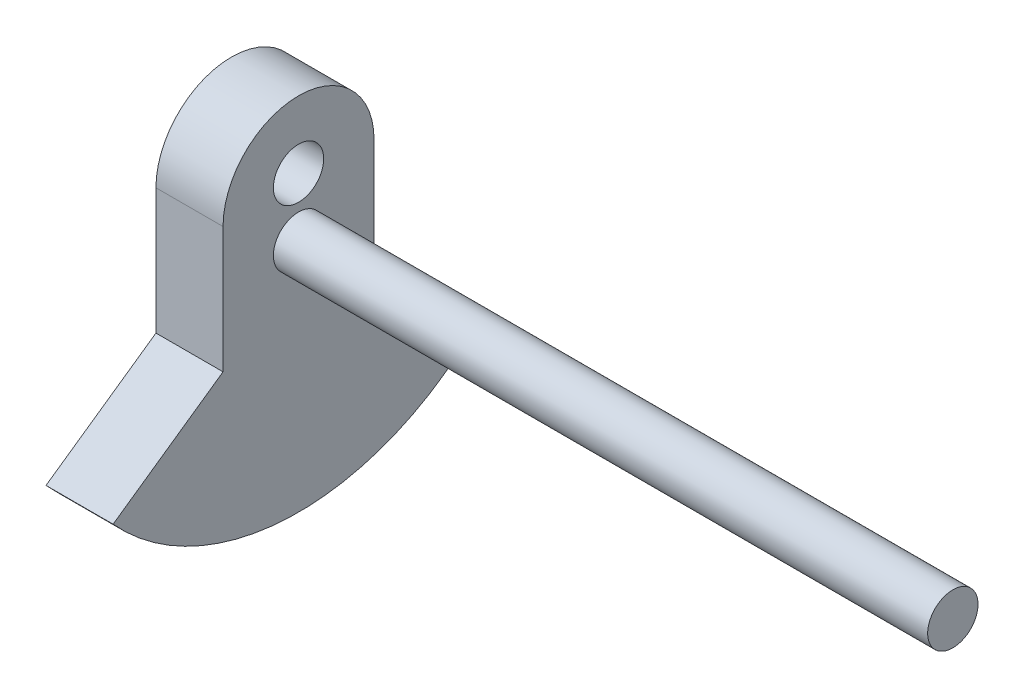
from build123d import *

# Parameters (mm, degrees)
SKETCH1_R           = 1.5
BOSS_EXTRUDE1_DEPTH = 4
SKETCH1_2_R         = 1.5
BOSS_EXTRUDE2_DEPTH = 43
CUT_EXTRUDE1_REACH  = 45
SKETCH2_R           = 1.5


with BuildPart() as part:
    # Sketch1 → Boss-Extrude1 (new body)
    with BuildSketch(Plane(origin=(0, 0, 0), x_dir=(0, 0, -1), z_dir=(1, 0, 0))):
        with BuildLine():
            Line((-4.5, -4.5), (-4.5, 3))
            ThreePointArc((-4.5, 3), (0, 7.5), (4.5, 3))
            Line((4.5, 3), (4.5, -4.5))
            Line((4.5, -4.5), (11.053216354, -9.088611491))
            ThreePointArc((11.053216354, -9.088611491), (0, -14), (-11.053216354, -9.088611491))
            Line((-11.053216354, -9.088611491), (-4.5, -4.5))
        make_face()
        Circle(SKETCH1_R, mode=Mode.SUBTRACT)
    extrude(amount=BOSS_EXTRUDE1_DEPTH)

    # Sketch1_2 → Boss-Extrude2 (add)
    with BuildSketch(Plane(origin=(0, 0, 0), x_dir=(0, 0, -1), z_dir=(1, 0, 0))):
        Circle(SKETCH1_2_R)
    extrude(amount=BOSS_EXTRUDE2_DEPTH)

    # Sketch2 → Cut-Extrude1 (cut, up to next)
    with BuildSketch(Plane.ZY, mode=Mode.PRIVATE) as cut_extrude1_sk1:
        with Locations((0, 3.5)):
            Circle(SKETCH2_R)
    cut_extrude1_tool1 = extrude(cut_extrude1_sk1.sketch, amount=-CUT_EXTRUDE1_REACH, mode=Mode.PRIVATE) & part.part
    add(cut_extrude1_tool1.solids().sort_by_distance((0, 3.5, 0))[0], mode=Mode.SUBTRACT)


solid = part.part
